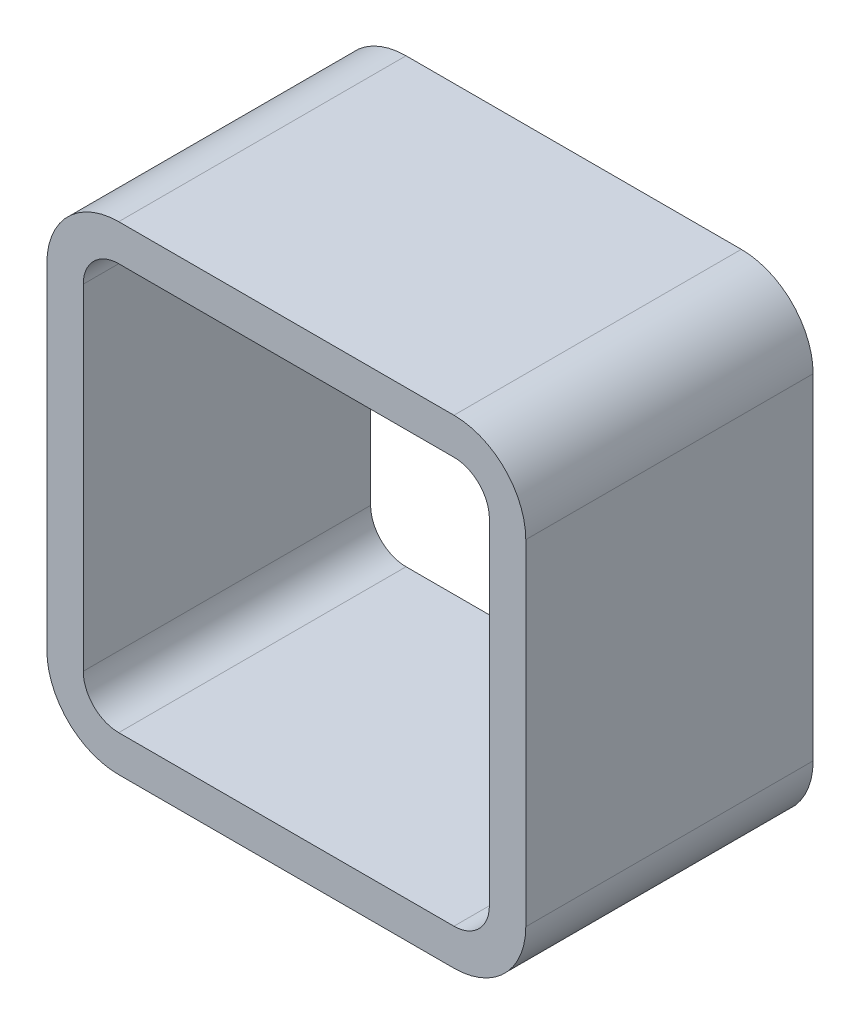
from build123d import *

# Parameters (mm, degrees)
BOSS_EXTRUDE1_DEPTH = 19.05


with BuildPart() as part:
    # Sketch1 → Boss-Extrude1 (new body)
    with BuildSketch(Plane.XY):
        with BuildLine():
            Line((-11.1125, 15.875), (11.1125, 15.875))
            ThreePointArc((11.1125, 15.875), (14.480096045, 14.480096045), (15.875, 11.1125))
            Line((15.875, 11.1125), (15.875, -11.1125))
            ThreePointArc((15.875, -11.1125), (14.480096045, -14.480096045), (11.1125, -15.875))
            Line((11.1125, -15.875), (-11.1125, -15.875))
            ThreePointArc((-11.1125, -15.875), (-14.480096045, -14.480096045), (-15.875, -11.1125))
            Line((-15.875, -11.1125), (-15.875, 11.1125))
            ThreePointArc((-15.875, 11.1125), (-14.480096045, 14.480096045), (-11.1125, 15.875))
        make_face()
        with BuildLine():
            Line((-11.1125, 13.462), (11.1125, 13.462))
            ThreePointArc((11.1125, 13.462), (12.773847382, 12.773847382), (13.462, 11.1125))
            Line((13.462, 11.1125), (13.462, -11.1125))
            ThreePointArc((13.462, -11.1125), (12.773847382, -12.773847382), (11.1125, -13.462))
            Line((11.1125, -13.462), (-11.1125, -13.462))
            ThreePointArc((-11.1125, -13.462), (-12.773847382, -12.773847382), (-13.462, -11.1125))
            Line((-13.462, -11.1125), (-13.462, 11.1125))
            ThreePointArc((-13.462, 11.1125), (-12.773847382, 12.773847382), (-11.1125, 13.462))
        make_face(mode=Mode.SUBTRACT)
    extrude(amount=BOSS_EXTRUDE1_DEPTH)


solid = part.part
